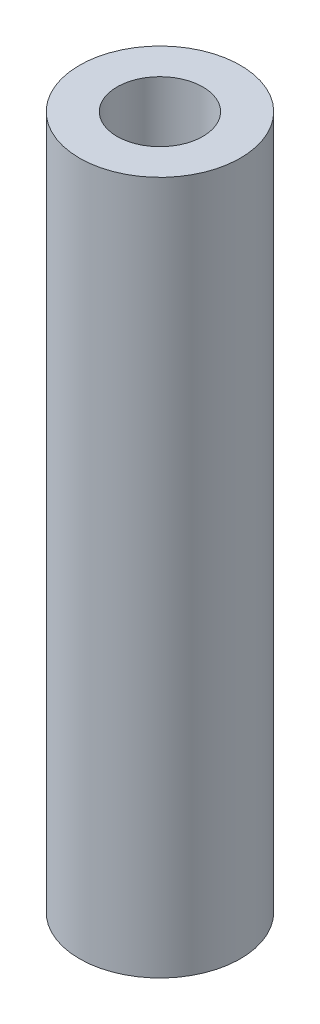
from build123d import *

# Parameters (mm, degrees)
PROFILE_SKETCH_R      = 3
PROFILE_SKETCH_R_2    = 1.6
PROFILE_EXTRUDE_DEPTH = 25.8572


with BuildPart() as part:
    # Profile Sketch → Profile Extrude (new body)
    with BuildSketch(Plane(origin=(0, 0, 0), x_dir=(1, 0, 0), z_dir=(0, 1, 0))):
        Circle(PROFILE_SKETCH_R)
        Circle(PROFILE_SKETCH_R_2, mode=Mode.SUBTRACT)
    extrude(amount=PROFILE_EXTRUDE_DEPTH)


solid = part.part
